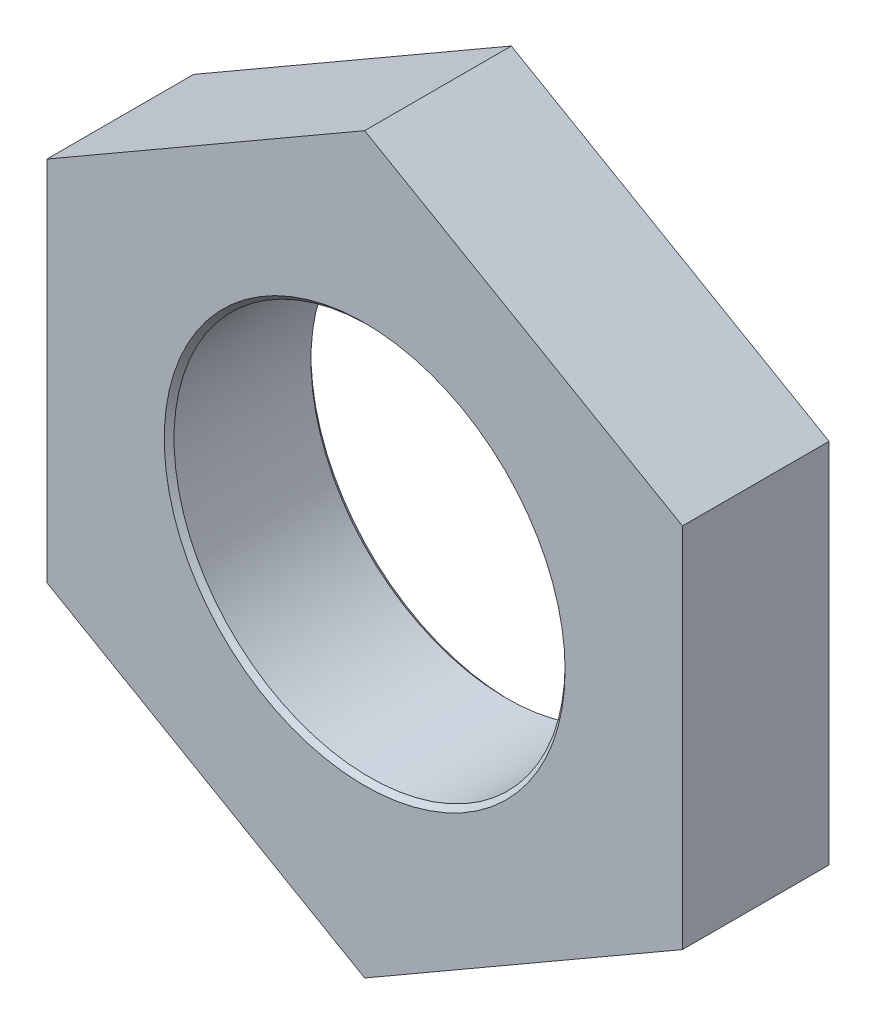
from build123d import *

# Parameters (mm, degrees)
EXTRUDE_1_DEPTH     = 3
SKETCH_2_R          = 4
CUT_EXTRUDE_1_DEPTH = 3
CHAMFER_1_SIZE      = 0.1


with BuildPart() as part:
    # 草图1 → 凸台-拉伸1 (new body)
    with BuildSketch(Plane.XY):
        Polygon((0, 7.505553499), (-6.5, 3.75277675), (-6.5, -3.75277675), (0, -7.505553499), (6.5, -3.75277675), (6.5, 3.75277675), align=None)
    extrude(amount=-EXTRUDE_1_DEPTH)

    # 草图2 → 切除-拉伸1 (cut)
    with BuildSketch(Plane.XY):
        Circle(SKETCH_2_R)
    extrude(amount=-CUT_EXTRUDE_1_DEPTH, mode=Mode.SUBTRACT)

    # 倒角1
    chamfer_1_edges = [part.edges().sort_by_distance(p)[0] for p in [
        (-4, 0, -3),
        (-4, 0, 0),
    ]]
    chamfer(chamfer_1_edges, length=CHAMFER_1_SIZE)


solid = part.part
